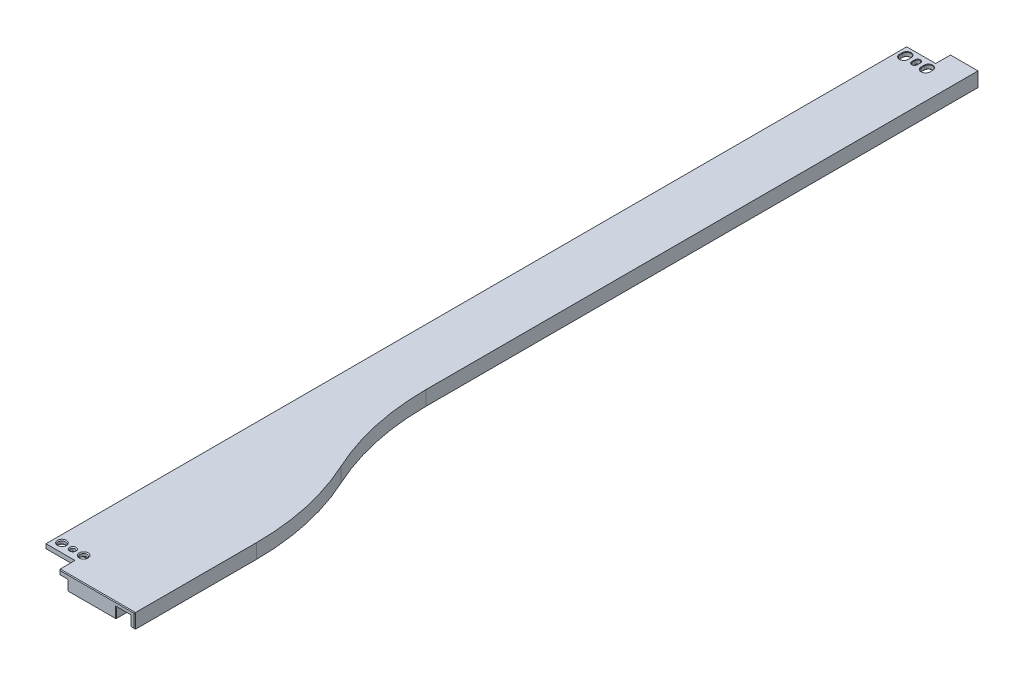
from build123d import *

# Parameters (mm, degrees)
EXTRUDE1_DEPTH                 = 10
EXTRUDE2_DEPTH                 = 7
SKETCH5_W                      = 20
SKETCH5_H                      = 15
SKETCH5_W_2                    = 26
EXTRUDE3_DEPTH                 = 7
SKETCH15_W                     = 6
SKETCH15_H                     = 10.7
SKETCH15_H_2                   = 25.7
EXTRUDE9_DEPTH                 = 7
F_8_CLEARANCE_HOLE1_AT_2_COUNT = 2
F_8_CLEARANCE_HOLE1_AT_2_PITCH = 15
EXTRUDE6_DEPTH                 = 4
SKETCH16_R                     = 1.5875
EXTRUDE10_DEPTH                = 7
CHAMFER1_SIZE                  = 0.3
CHAMFER2_SIZE                  = 0.5
CHAMFER3_SIZE                  = 0.3
FILLET3_R                      = 3
FILLET2_R                      = 0.5


with BuildPart() as part:
    # Sketch1 → Extrude1 (new body)
    with BuildSketch(Plane(origin=(0, 0, 0), x_dir=(1, 0, 0), z_dir=(0, 1, 0))):
        with BuildLine():
            Line((-93.1, 756.2), (-145.1, 756.2))
            Line((-145.1, 756.2), (-145.1, 766.9))
            Line((-145.1, 766.9), (-165.1, 766.9))
            Line((-165.1, 766.9), (-165.1, 1360.9))
            Line((-165.1, 1360.9), (-145.1, 1360.9))
            Line((-145.1, 1360.9), (-145.1, 1371.6))
            Line((-145.1, 1371.6), (-126.1, 1371.6))
            Line((-126.1, 1371.6), (-126.1, 990))
            ThreePointArc((-126.1, 990), (-121.926260039, 951.603222791), (-109.6, 915))
            ThreePointArc((-109.6, 915), (-97.273739961, 878.396777209), (-93.1, 840))
            Line((-93.1, 840), (-93.1, 756.2))
        make_face()
    extrude(amount=-EXTRUDE1_DEPTH)

    # Sketch4 → Extrude2 (cut)
    with BuildSketch(Plane.XZ.offset(10)):
        with BuildLine():
            Line((-165.1, -789.4), (-106.1, -789.4))
            Line((-106.1, -789.4), (-106.1, -756.2))
            Line((-106.1, -756.2), (-96.1, -756.2))
            Line((-96.1, -756.2), (-96.1, -840))
            ThreePointArc((-96.1, -840), (-100.203673361, -877.75219186), (-112.323006486, -913.740938573))
            ThreePointArc((-112.323006486, -913.740938573), (-124.856193439, -950.958637443), (-129.1, -990))
            Line((-129.1, -990), (-129.1, -1371.6))
            Line((-129.1, -1371.6), (-139.1, -1371.6))
            Line((-139.1, -1371.6), (-139.1, -1338.4))
            Line((-139.1, -1338.4), (-165.1, -1338.4))
            Line((-165.1, -1338.4), (-165.1, -789.4))
        make_face()
    extrude(amount=-EXTRUDE2_DEPTH, mode=Mode.SUBTRACT)

    # Sketch5 → Extrude3 (cut)
    with BuildSketch(Plane.XZ.offset(10)):
        with Locations((-155.1, -774.4)):
            Rectangle(SKETCH5_W, SKETCH5_H)
        with Locations((-152.1, -1353.4)):
            Rectangle(SKETCH5_W_2, SKETCH5_H)
    extrude(amount=-EXTRUDE3_DEPTH, mode=Mode.SUBTRACT)

    # Sketch15 → Extrude9 (cut)
    with BuildSketch(Plane.XZ.offset(10)):
        with Locations((-142.1, -1366.25)):
            Rectangle(SKETCH15_W, SKETCH15_H)
        with Locations((-142.1, -769.05)):
            Rectangle(SKETCH15_W, SKETCH15_H_2)
    extrude(amount=-EXTRUDE9_DEPTH, mode=Mode.SUBTRACT)

    # Sketch9 → 1/8 (0.125) Diameter Hole1 (revolve, cut)
    with BuildSketch(Plane(origin=(-152.6, -3, -772.9), x_dir=(0, 0, -1), z_dir=(1, 0, 0))):
        Polygon((0, 0), (0, 3), (2.2479, 3), (1.6129, 2.365), (1.6129, 0.635), (2.2479, 0), align=None)
    revolve(axis=Axis((-152.6, -9.35, -772.9), (0, 1, 0)), mode=Mode.SUBTRACT)

    # Sketch10 → #8 Clearance Hole1 (revolve, cut)
    with BuildSketch(Plane(origin=(-160.1, -3, -772.9), x_dir=(0, 0, -1), z_dir=(1, 0, 0))):
        Polygon((0, 0), (0, 3), (3.09245, 3), (2.45745, 2.365), (2.45745, 0.635), (3.09245, 0), align=None)
    f_8_clearance_hole1 = revolve(axis=Axis((-160.1, -9.35, -772.9), (0, 1, 0)), mode=Mode.SUBTRACT)

    # #8 Clearance Hole1 at 2: #8 Clearance Hole1 ×2
    with Locations(*[(i * F_8_CLEARANCE_HOLE1_AT_2_PITCH, 0, 0) for i in range(1, F_8_CLEARANCE_HOLE1_AT_2_COUNT)]):
        add(f_8_clearance_hole1, mode=Mode.SUBTRACT)

    # Sketch12 → Extrude6 (cut, through all)
    with BuildSketch(Plane.XZ.offset(3)):
        with BuildLine():
            Line((-154.251, -1353.9), (-154.251, -1355.9))
            ThreePointArc((-154.251, -1355.9), (-152.6, -1357.551), (-150.949, -1355.9))
            Line((-150.949, -1355.9), (-150.949, -1353.9))
            ThreePointArc((-150.949, -1353.9), (-152.6, -1352.249), (-154.251, -1353.9))
        make_face()
        with BuildLine():
            Line((-142.35, -1353.9), (-142.35, -1355.9))
            ThreePointArc((-142.35, -1355.9), (-145.1, -1358.65), (-147.85, -1355.9))
            Line((-147.85, -1355.9), (-147.85, -1353.9))
            ThreePointArc((-147.85, -1353.9), (-145.1, -1351.15), (-142.35, -1353.9))
        make_face()
        with BuildLine():
            Line((-162.85, -1353.9), (-162.85, -1355.9))
            ThreePointArc((-162.85, -1355.9), (-160.1, -1358.65), (-157.35, -1355.9))
            Line((-157.35, -1355.9), (-157.35, -1353.9))
            ThreePointArc((-157.35, -1353.9), (-160.1, -1351.15), (-162.85, -1353.9))
        make_face()
    extrude(amount=-EXTRUDE6_DEPTH, mode=Mode.SUBTRACT)

    # Sketch16 → Extrude10 (cut)
    with BuildSketch(Plane.XZ.offset(10)):
        with Locations((-139.1, -780.3125)):
            Circle(SKETCH16_R)
    extrude(amount=-EXTRUDE10_DEPTH, mode=Mode.SUBTRACT)

    # Chamfer1
    chamfer1_edges = [part.edges().sort_by_distance(p)[0] for p in [
        (-152.6, 0, -1352.249),
        (-150.949, 0, -1354.9),
        (-152.6, 0, -1357.551),
        (-154.251, 0, -1354.9),
        (-152.6, -3, -1352.249),
        (-154.251, -3, -1354.9),
        (-152.6, -3, -1357.551),
        (-150.949, -3, -1354.9),
    ]]
    chamfer(chamfer1_edges, length=CHAMFER1_SIZE)

    # Chamfer2
    chamfer2_edges = [part.edges().sort_by_distance(p)[0] for p in [
        (-94.6, -10, -756.2),
        (-93.1, -5, -756.2),
        (-119.1, 0, -756.2),
        (-145.1, -1.5, -756.2),
        (-106.1, -6.5, -756.2),
        (-101.1, -3, -756.2),
        (-96.1, -6.5, -756.2),
        (-126.1, -5, -1371.6),
        (-127.6, -10, -1371.6),
        (-129.1, -6.5, -1371.6),
        (-137.1, -3, -1371.6),
        (-145.1, -1.5, -1371.6),
        (-135.6, 0, -1371.6),
    ]]
    chamfer(chamfer2_edges, length=CHAMFER2_SIZE)

    # Chamfer3
    chamfer3_edges = [part.edges().sort_by_distance(p)[0] for p in [
        (-145.1, 0, -1351.15),
        (-142.35, 0, -1354.9),
        (-145.1, 0, -1358.65),
        (-147.85, 0, -1354.9),
        (-145.1, -3, -1351.15),
        (-147.85, -3, -1354.9),
        (-145.1, -3, -1358.65),
        (-142.35, -3, -1354.9),
        (-160.1, 0, -1351.15),
        (-157.35, 0, -1354.9),
        (-160.1, 0, -1358.65),
        (-162.85, 0, -1354.9),
        (-160.1, -3, -1351.15),
        (-162.85, -3, -1354.9),
        (-160.1, -3, -1358.65),
        (-157.35, -3, -1354.9),
    ]]
    chamfer(chamfer3_edges, length=CHAMFER3_SIZE)

    # Fillet3
    fillet3_edges = [part.edges().sort_by_distance(p)[0] for p in [
        (-106.1, -6.5, -789.4),
        (-139.1, -6.5, -1338.4),
        (-139.1, -6.5, -1345.9),
    ]]
    fillet(fillet3_edges, radius=FILLET3_R)

    # Fillet2
    fillet2_edges = [part.edges().sort_by_distance(p)[0] for p in [
        (-139.1, -3, -767.4625),
        (-137.5125, -3, -780.3125),
        (-96.1, -3, -798.35),
        (-139.1, -3, -1342.15),
        (-153.6, -3, -1338.4),
        (-106.1, -3, -771.55),
        (-139.978679656, -3, -1339.278679656),
        (-139.978679656, -3, -1345.021320344),
        (-106.978679656, -3, -788.521320344),
        (-137.1, -3, -789.4),
        (-100.203673361, -3, -877.75219186),
        (-124.856193439, -3, -950.958637443),
        (-129.1, -3, -1180.55),
        (-153.6, -3, -1345.9),
        (-152.1, -3, -781.9),
    ]]
    fillet(fillet2_edges, radius=FILLET2_R)


solid = part.part
